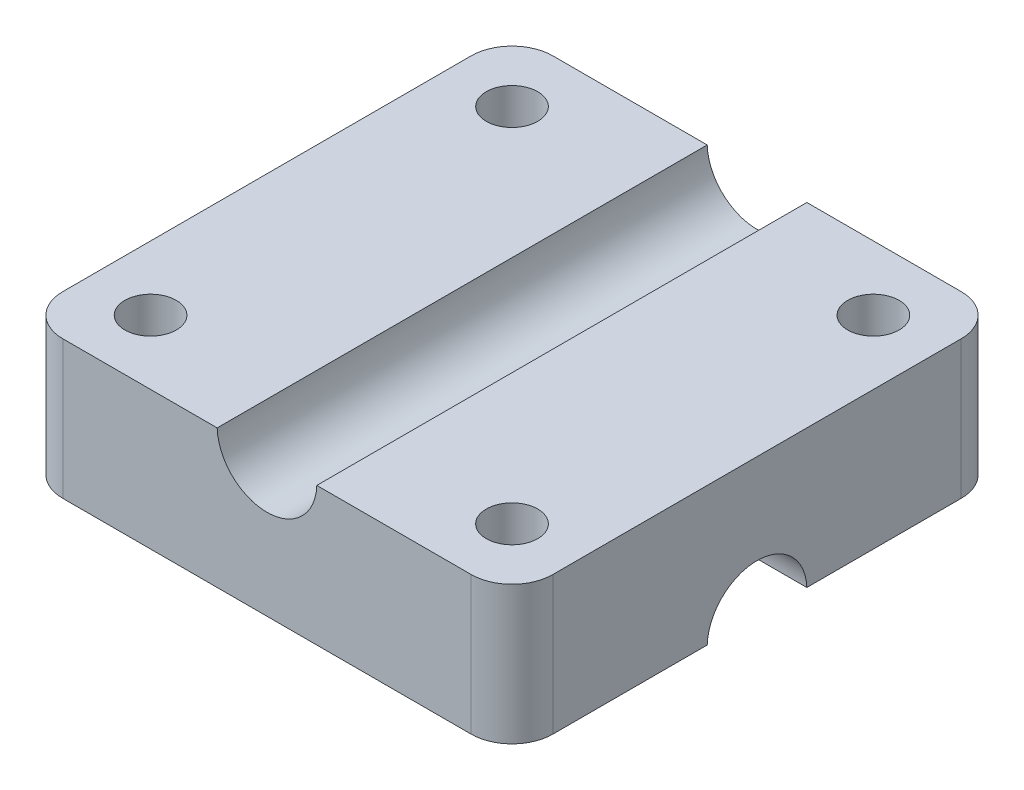
from build123d import *

# Parameters (mm, degrees)
SKETCH_2_W          = 30.48
SKETCH_2_H          = 30.48
EXTRUDE_1_DEPTH     = 8.6
SKETCH_3_R          = 3.1
CUT_EXTRUDE_1_DEPTH = 30.48
SKETCH_4_R          = 3.1
CUT_EXTRUDE_2_DEPTH = 30.48
SKETCH_5_R          = 1.6
CUT_EXTRUDE_3_DEPTH = 9.6
FILLET_2_R          = 2.54


with BuildPart() as part:
    # 草图2 → 凸台-拉伸1 (new body)
    with BuildSketch(Plane(origin=(0, 0, 0), x_dir=(1, 0, 0), z_dir=(0, 1, 0))):
        Rectangle(SKETCH_2_W, SKETCH_2_H)
    extrude(amount=EXTRUDE_1_DEPTH)

    # 草图3 → 切除-拉伸1 (cut)
    with BuildSketch(Plane.XY.offset(15.24)):
        with Locations((0, 8.7)):
            Circle(SKETCH_3_R)
    extrude(amount=-CUT_EXTRUDE_1_DEPTH, mode=Mode.SUBTRACT)

    # 草图4 → 切除-拉伸2 (cut)
    with BuildSketch(Plane(origin=(15.24, 0, 0), x_dir=(0, 0, -1), z_dir=(1, 0, 0))):
        with Locations((0, -0.1)):
            Circle(SKETCH_4_R)
    extrude(amount=-CUT_EXTRUDE_2_DEPTH, mode=Mode.SUBTRACT)

    # 草图5 → 切除-拉伸3 (cut, through all)
    with BuildSketch(Plane.XZ):
        with Locations((-11.24, 11.24)):
            Circle(SKETCH_5_R)
        with Locations((11.24, 11.24)):
            Circle(SKETCH_5_R)
        with Locations((11.24, -11.24)):
            Circle(SKETCH_5_R)
        with Locations((-11.24, -11.24)):
            Circle(SKETCH_5_R)
    extrude(amount=-CUT_EXTRUDE_3_DEPTH, mode=Mode.SUBTRACT)

    # 圆角2
    fillet_2_edges = [part.edges().sort_by_distance(p)[0] for p in [
        (15.24, 4.3, 15.24),
        (-15.24, 4.3, 15.24),
        (-15.24, 4.3, -15.24),
        (15.24, 4.3, -15.24),
    ]]
    fillet(fillet_2_edges, radius=FILLET_2_R)


solid = part.part
